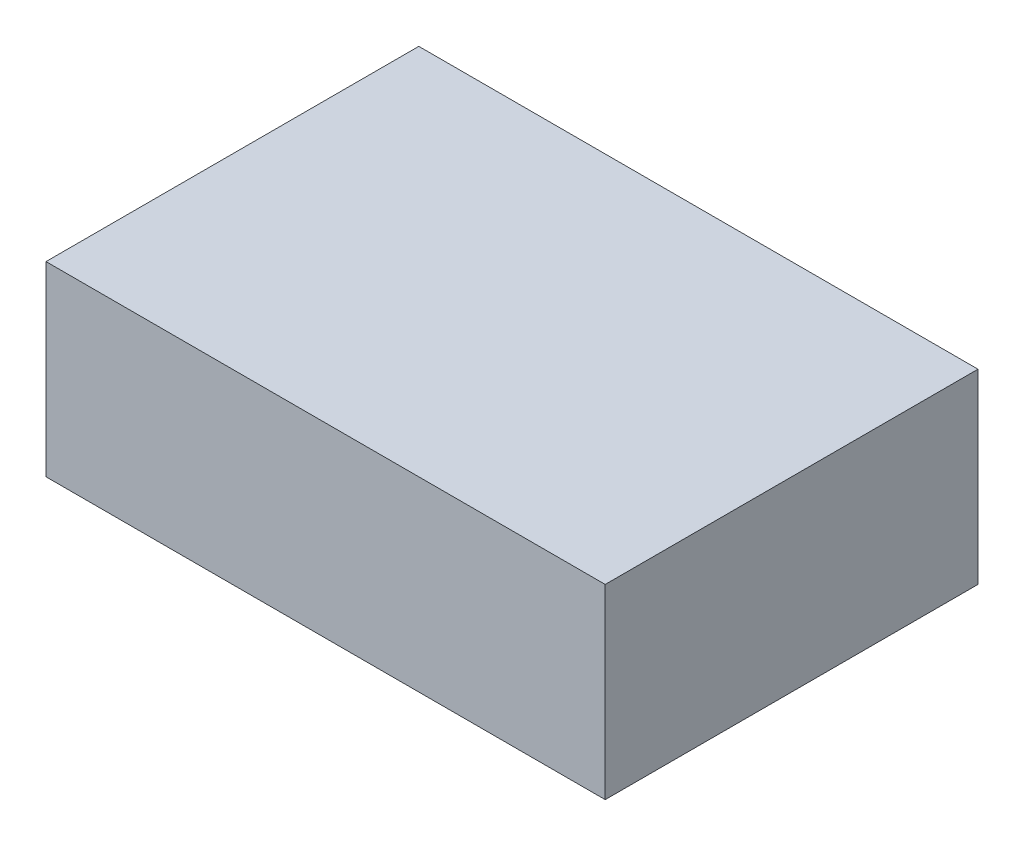
from build123d import *

# Parameters (mm, degrees)
BASES_W    = 1.2
BASES_H    = 0.8
BASE_DEPTH = 0.4


with BuildPart() as part:
    # BaseS → Base (new body)
    with BuildSketch(Plane(origin=(0, 0, 0), x_dir=(1, 0, 0), z_dir=(0, 1, 0))):
        Rectangle(BASES_W, BASES_H)
    extrude(amount=BASE_DEPTH)


solid = part.part
